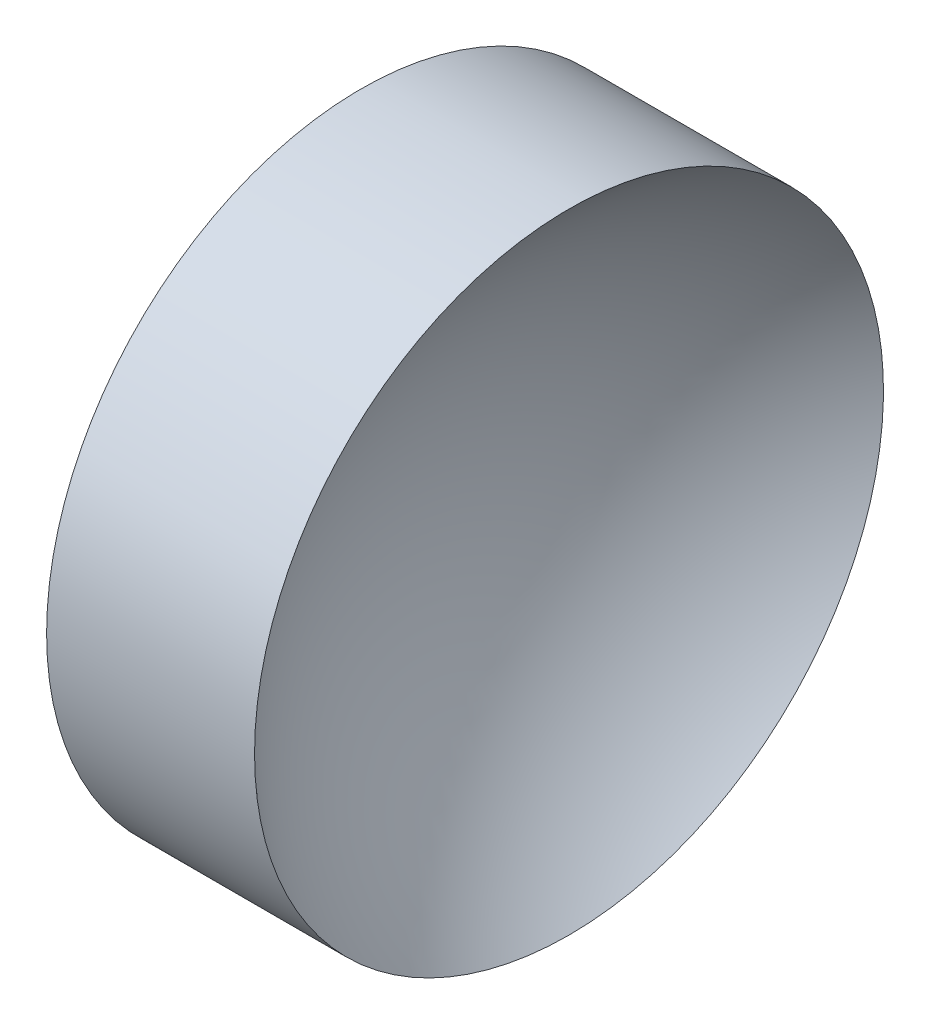
from build123d import *


with BuildPart() as part:
    # 草图1 → 旋转1 (revolve)
    with BuildSketch(Plane.XY, mode=Mode.PRIVATE) as revolve_1_sk:
        with BuildLine():
            Line((44.319152693, 26.089041149), (44.319152693, 34.089041149))
            Line((44.319152693, 34.089041149), (49.609152693, 34.089041149))
            ThreePointArc((49.609152693, 34.089041149), (46.814574888, 30.515216134), (45.819152693, 26.089041149))
            Line((45.819152693, 26.089041149), (44.319152693, 26.089041149))
        make_face()
    revolve(revolve_1_sk.sketch.rotate(Axis((42.449861114, 26.089041149, 0), (1, 0, 0)), 180), axis=Axis((42.449861114, 26.089041149, 0), (1, 0, 0)))  # turned: the seam where the file's is


solid = part.part
